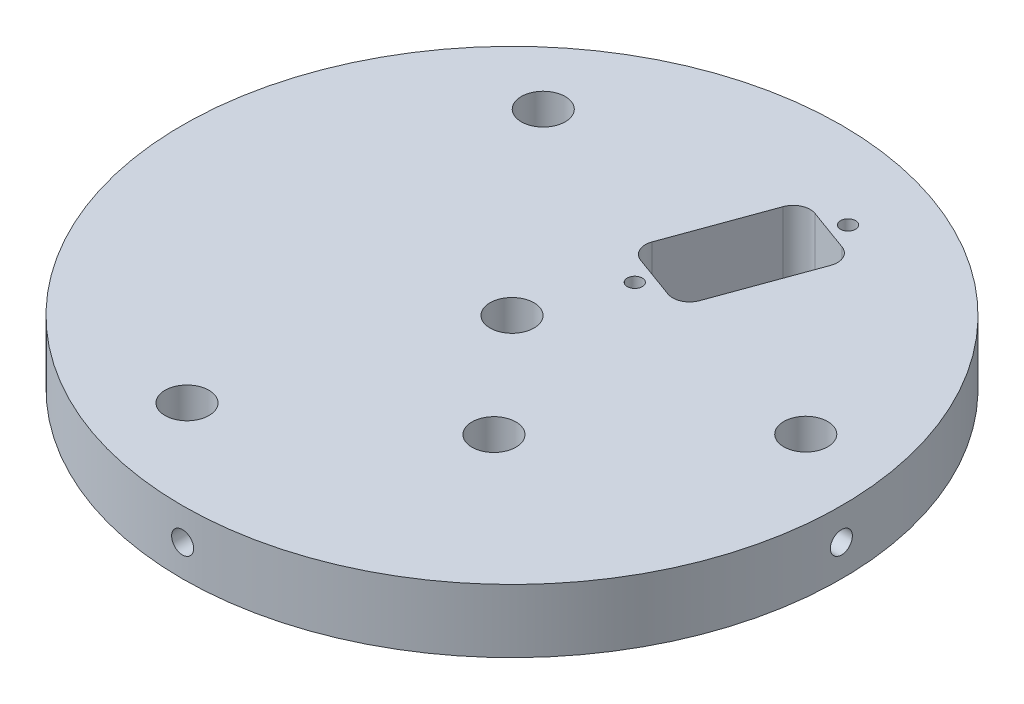
from build123d import *

# Parameters (mm, degrees)
SKETCH1_R                 = 78.359
SKETCH1_R_2               = 51.1048
BOSS_EXTRUDE1_DEPTH       = 25.4
SKETCH6_R                 = 49.5173
BOSS_EXTRUDE5_DEPTH       = 9.525
SKETCH7_R                 = 49.5173
BOSS_EXTRUDE6_DEPTH       = 9.525
SKETCH9_R                 = 3.3
CUT_EXTRUDE6_DEPTH        = 120.39877831
SKETCH10_R                = 82.322787435
CUT_EXTRUDE7_DEPTH        = 117.189592421
TAP_DRILL_FOR_4_40_TAP1_D = 2.2606
CUT_EXTRUDE9_DEPTH        = 71.672849267
CIRPATTERN1_COUNT         = 4


with BuildPart() as part:
    # Sketch1 → Boss-Extrude1 (new body)
    with BuildSketch(Plane(origin=(0, 0, 0), x_dir=(1, 0, 0), z_dir=(0, 1, 0))):
        Circle(SKETCH1_R)
        Circle(SKETCH1_R_2, mode=Mode.SUBTRACT)
    extrude(amount=BOSS_EXTRUDE1_DEPTH)


with BuildPart() as body_2:
    # Sketch6 → Boss-Extrude5 (new body)
    with BuildSketch(Plane(origin=(0, 25.4, 0), x_dir=(1, 0, 0), z_dir=(0, 1, 0))):
        Circle(SKETCH6_R)
    extrude(amount=BOSS_EXTRUDE5_DEPTH)


with BuildPart() as body_3:
    # Sketch7 → Boss-Extrude6 (new body)
    with BuildSketch(Plane.XZ):
        Circle(SKETCH7_R)
    extrude(amount=BOSS_EXTRUDE6_DEPTH)


with BuildPart() as cut_extrude6_tool:
    # Sketch9 → Cut-Extrude6 (new, through all)
    with BuildSketch(Plane(origin=(0, 34.925, 0), x_dir=(1, 0, 0), z_dir=(0, 1, 0))):
        Circle(SKETCH9_R)
        with Locations((-13.030967461, -35.802288852)):
            Circle(SKETCH9_R)
        with Locations((14.149897915, -16.863191675)):
            Circle(SKETCH9_R)
        with Locations((-24.490207929, 29.186293283)):
            Circle(SKETCH9_R)
        with Locations((37.52117539, 6.615995569)):
            Circle(SKETCH9_R)
    extrude(amount=-CUT_EXTRUDE6_DEPTH)


with BuildPart() as body_2_1:
    add(body_2.part)

    # Cut-Extrude6: cut by cut_extrude6_tool
    add(cut_extrude6_tool.part, mode=Mode.SUBTRACT)

    # Tap Drill for _4-40 Tap1 (through all)
    with Locations(Plane(origin=(0, 34.925, 0), x_dir=(1, 0, 0), z_dir=(0, 1, 0))):
        with Locations((4.92280993, 13.525309122), (13.473313526, 37.017624677)):
            Hole(TAP_DRILL_FOR_4_40_TAP1_D / 2)

    # Sketch14 → Cut-Extrude9 (cut, through all)
    with BuildSketch(Plane(origin=(0, 34.925, 0), x_dir=(1, 0, 0), z_dir=(0, 1, 0))):
        with BuildLine():
            Line((12.182424395, 16.018747474), (17.431749568, 30.441149854))
            ThreePointArc((17.431749568, 30.441149854), (17.34695209, 32.383331403), (15.913661475, 33.696700275))
            Line((15.913661475, 33.696700275), (9.469249481, 36.042274418))
            ThreePointArc((9.469249481, 36.042274418), (7.527067933, 35.95747694), (6.213699061, 34.524186325))
            Line((6.213699061, 34.524186325), (0.964373888, 20.101783945))
            ThreePointArc((0.964373888, 20.101783945), (1.049171366, 18.159602396), (2.482461981, 16.846233524))
            Line((2.482461981, 16.846233524), (8.926873974, 14.500659381))
            ThreePointArc((8.926873974, 14.500659381), (10.869055523, 14.585456859), (12.182424395, 16.018747474))
        make_face()
    extrude(amount=-CUT_EXTRUDE9_DEPTH, mode=Mode.SUBTRACT)

    # Sketch17 → Tap Drill for M4x0.7 Tap1 (revolve, cut)
    with BuildSketch(Plane(origin=(49.5173, 30.1625, 0), x_dir=(0, 0, -1), z_dir=(0, 1, 0))):
        Polygon((0, 0), (0, 10.643420021), (1.65, 9.652), (1.65, 0), align=None)
    tap_drill_for_m4x0_7_tap1 = revolve(axis=Axis((55.8673, 30.1625, 0), (-1, 0, 0)), mode=Mode.SUBTRACT)

    # CirPattern1: Tap Drill for M4x0.7 Tap1 ×4 about axis
    cirpattern1_axis = Axis((0, 34.925, 0), (0, 1, 0))
    for i in range(1, CIRPATTERN1_COUNT):
        add(tap_drill_for_m4x0_7_tap1.rotate(cirpattern1_axis, i * 360 / CIRPATTERN1_COUNT), mode=Mode.SUBTRACT)


with BuildPart() as body_3_1:
    add(body_3.part)

    # Cut-Extrude6: cut by cut_extrude6_tool
    add(cut_extrude6_tool.part, mode=Mode.SUBTRACT)


with BuildPart() as cut_extrude7_tool:
    # Sketch10 → Cut-Extrude7 (new, through all)
    with BuildSketch(Plane(origin=(0, 25.4, 0), x_dir=(1, 0, 0), z_dir=(0, 1, 0))):
        Circle(SKETCH10_R)
    extrude(amount=-CUT_EXTRUDE7_DEPTH)


with BuildPart() as part_1:
    add(part.part)

    # Cut-Extrude7: cut by cut_extrude7_tool
    add(cut_extrude7_tool.part, mode=Mode.SUBTRACT)


with BuildPart() as body_3_2:
    add(body_3_1.part)

    # Cut-Extrude7: cut by cut_extrude7_tool
    add(cut_extrude7_tool.part, mode=Mode.SUBTRACT)


solid = body_2_1.part
